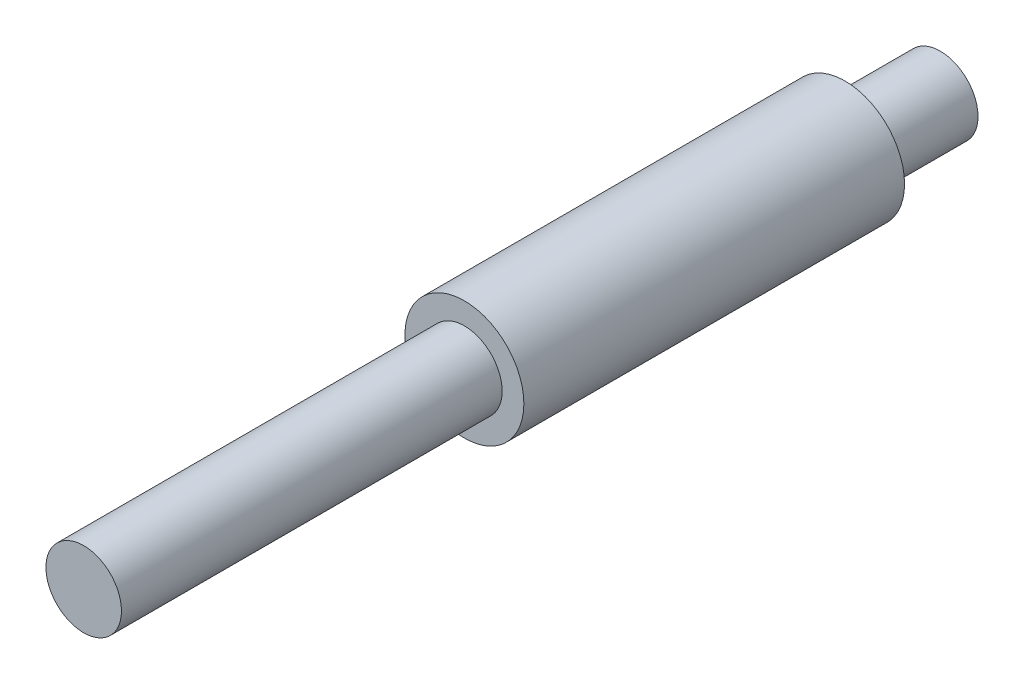
from build123d import *

# Parameters (mm, degrees)
SKETCH1_R                = 2.5
BOSS_EXTRUDE1_DEPTH      = 16
SKETCH2_R                = 1.5875
BOSS_EXTRUDE2_DEPTH      = 16
BOSS_EXTRUDE2_DEPTH_BACK = 20


with BuildPart() as part:
    # Sketch1 → Boss-Extrude1 (new body)
    with BuildSketch(Plane.XY):
        Circle(SKETCH1_R)
    extrude(amount=BOSS_EXTRUDE1_DEPTH)

    # Sketch2 → Boss-Extrude2 (add, two sides)
    with BuildSketch(Plane.XY.offset(16)) as boss_extrude2_sk:
        Circle(SKETCH2_R)
    extrude(amount=BOSS_EXTRUDE2_DEPTH)
    extrude(boss_extrude2_sk.sketch, amount=-BOSS_EXTRUDE2_DEPTH_BACK)


solid = part.part
